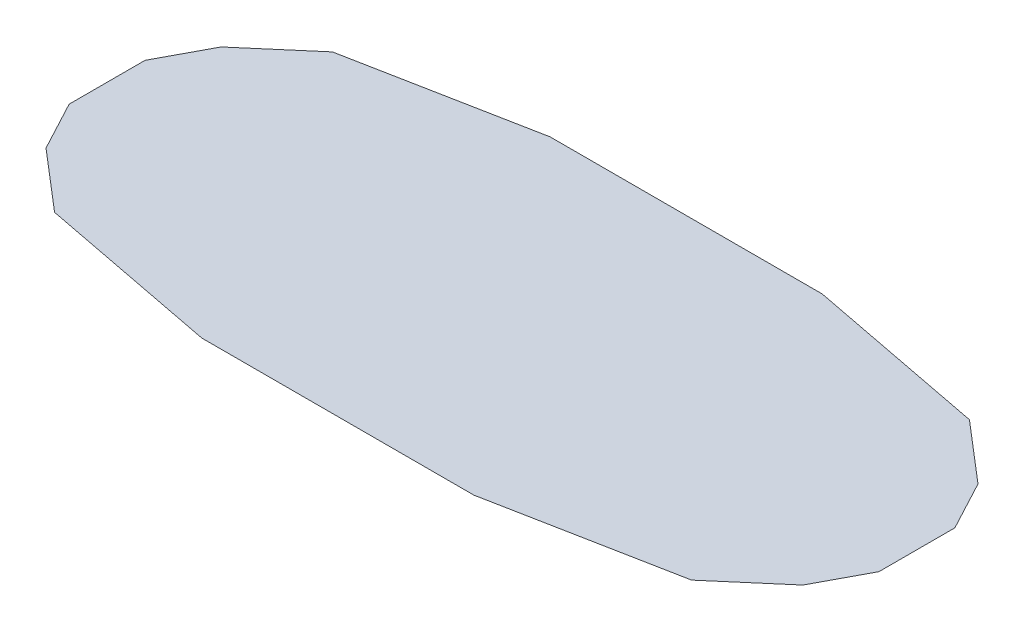
from build123d import *

# Parameters (mm, degrees)
BOSS_EXTRUDE1_DEPTH     = 5
CUT_EXTRUDE2_DEPTH      = 100
CUT_EXTRUDE2_DEPTH_BACK = 100


with BuildPart() as part:
    # Sketch1 → Boss-Extrude1 (new body)
    with BuildSketch(Plane(origin=(0, 0, 0), x_dir=(1, 0, 0), z_dir=(0, 1, 0))):
        Polygon((48.196890285, 40.561739349), (-48.196890285, 40.561739349), (-68.835657659, 34.23887998), (-95.439386703, 21.831759708), (-101.404348372, 15.747498806), (-101.404348372, -15.747498806), (-95.439386703, -21.831759708), (-68.835657659, -34.23887998), (-48.196890285, -40.561739349), (48.196890285, -40.561739349), (68.835657659, -34.23887998), (95.439386703, -21.831759708), (101.404348372, -15.747498806), (101.404348372, 15.747498806), (95.439386703, 21.831759708), (68.835657659, 34.23887998), align=None)
    extrude(amount=BOSS_EXTRUDE1_DEPTH)

    # Sketch2 → section 1 of loft2
    with BuildSketch(Plane(origin=(0, 37, 0), x_dir=(1, 0, 0), z_dir=(0, 1, 0)), mode=Mode.PRIVATE) as loft2_s1:
        with BuildLine():
            Line((-69.499566366, 86.559191019), (71.110487868, 86.559191019))
            Line((71.110487868, 86.559191019), (165.372648179, 68.335699669))
            Line((165.372648179, 68.335699669), (196.335556079, 41.796064326))
            Line((196.335556079, 41.796064326), (210, 16.175231975))
            Line((210, 16.175231975), (210, -23.056849936))
            Line((210, -23.056849936), (196.335556079, -48.677682288))
            Line((196.335556079, -48.677682288), (165.372648179, -75.217317631))
            Line((165.372648179, -75.217317631), (71.110487868, -93.440808981))
            Line((71.110487868, -93.440808981), (-69.499566366, -93.440808981))
            Line((-69.499566366, -93.440808981), (-163.761726677, -75.217317631))
            Line((-163.761726677, -75.217317631), (-194.724634578, -48.677682288))
            Line((-194.724634578, -48.677682288), (-208.389078498, -23.056849936))
            Line((-208.389078498, -23.056849936), (-208.389078498, 16.175231975))
            Line((-208.389078498, 16.175231975), (-194.724634578, 41.796064326))
            Line((-194.724634578, 41.796064326), (-163.761726677, 68.335699669))
            Line((-163.761726677, 68.335699669), (-69.499566366, 86.559191019))
        make_face()
    # loft from a face of the part (loft2)
    loft([part.faces().sort_by_distance((0, 5, 0))[0], loft2_s1.sketch])

    # Sketch4 → Cut-Extrude2 (cut, two sides: drawn at the far end of the back side and taken through both)
    with BuildSketch(Plane.XY.offset(-CUT_EXTRUDE2_DEPTH_BACK)):
        Polygon((-101.404348372, 5), (121.036097522, 5), (118.786130404, -29.699429441), (-111.783228991, -29.699429441), (-101.404348372, -4.949791143), align=None)
    extrude(amount=CUT_EXTRUDE2_DEPTH + CUT_EXTRUDE2_DEPTH_BACK, mode=Mode.SUBTRACT)


solid = part.part
